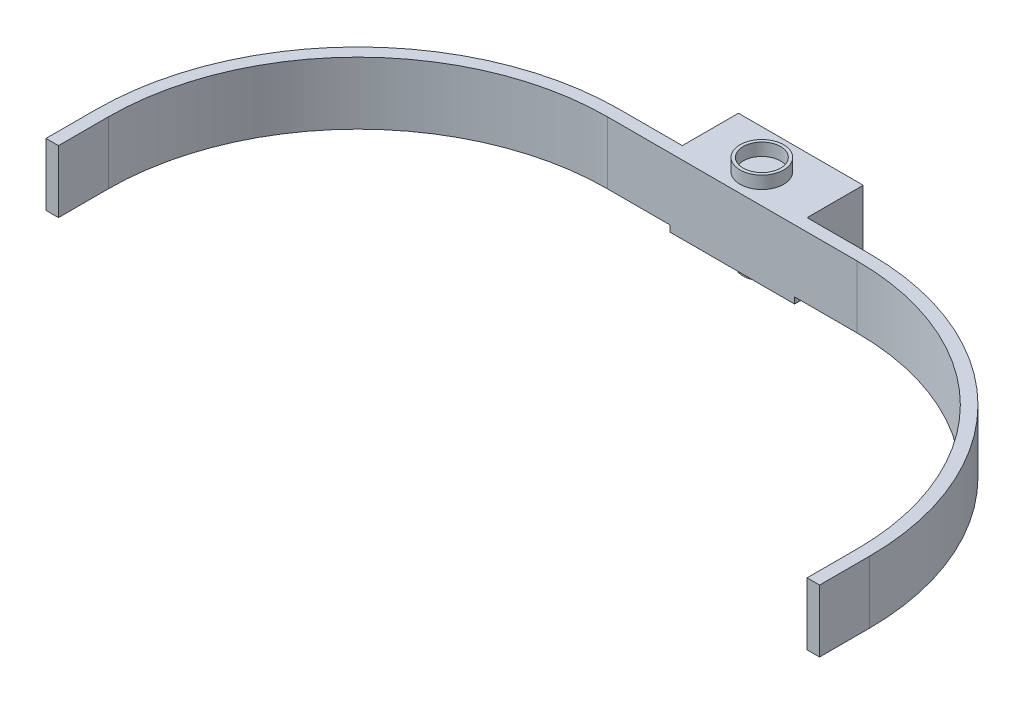
from build123d import *

# Parameters (mm, degrees)
EXTRUDE_1_DEPTH = 20
EXTRUDE_4_DEPTH = 20
SKETCH_10_W     = 40
SKETCH_10_H     = 18
EXTRUDE_5_DEPTH = 20
SKETCH_11_R     = 7
SKETCH_11_R_2   = 6
EXTRUDE_6_DEPTH = 4
SKETCH_12_R     = 6
EXTRUDE_7_DEPTH = 4


with BuildPart() as part:
    # 草图2 → 凸台-拉伸1 (new body, symmetric)
    with BuildSketch(Plane(origin=(0, 0, 0), x_dir=(0, 0, -1), z_dir=(1, 0, 0))):
        Polygon((-10, 1), (10, 1), (10, -1), (-10, -1), (-12, -1), (-12, 1), align=None)
    extrude(amount=EXTRUDE_1_DEPTH, both=True)

    # 草图9 → 凸台-拉伸4 (add)
    with BuildSketch(Plane(origin=(0, 1, 0), x_dir=(1, 0, 0), z_dir=(0, 1, 0))):
        with BuildLine():
            Line((-40, -8), (40, -8))
            ThreePointArc((40, -8), (99.39696962, -32.60303038), (124, -92))
            Line((124, -92), (124, -108))
            Line((124, -108), (120, -108))
            Line((120, -108), (120, -92))
            ThreePointArc((120, -92), (96.568542495, -35.431457505), (40, -12))
            Line((40, -12), (-40, -12))
            ThreePointArc((-40, -12), (-96.568542495, -35.431457505), (-120, -92))
            Line((-120, -92), (-120, -108))
            Line((-120, -108), (-124, -108))
            Line((-124, -108), (-124, -92))
            ThreePointArc((-124, -92), (-99.39696962, -32.60303038), (-40, -8))
        make_face()
    extrude(amount=EXTRUDE_4_DEPTH)

    # 草图10 → 凸台-拉伸5 (add)
    with BuildSketch(Plane(origin=(0, 1, 0), x_dir=(1, 0, 0), z_dir=(0, 1, 0))):
        with Locations((0, 1)):
            Rectangle(SKETCH_10_W, SKETCH_10_H)
    extrude(amount=EXTRUDE_5_DEPTH)

    # 草图11 → 凸台-拉伸6 (add)
    with BuildSketch(Plane(origin=(0, 21, 0), x_dir=(1, 0, 0), z_dir=(0, 1, 0))):
        with Locations((0, -2.5)):
            Circle(SKETCH_11_R)
        with Locations((0, -2.5)):
            Circle(SKETCH_11_R_2, mode=Mode.SUBTRACT)
    extrude(amount=EXTRUDE_6_DEPTH)

    # 草图12 → 凸台-拉伸7 (add)
    with BuildSketch(Plane.XZ.offset(1)):
        with Locations((0, 2.5)):
            Circle(SKETCH_12_R)
    extrude(amount=EXTRUDE_7_DEPTH)


solid = part.part
